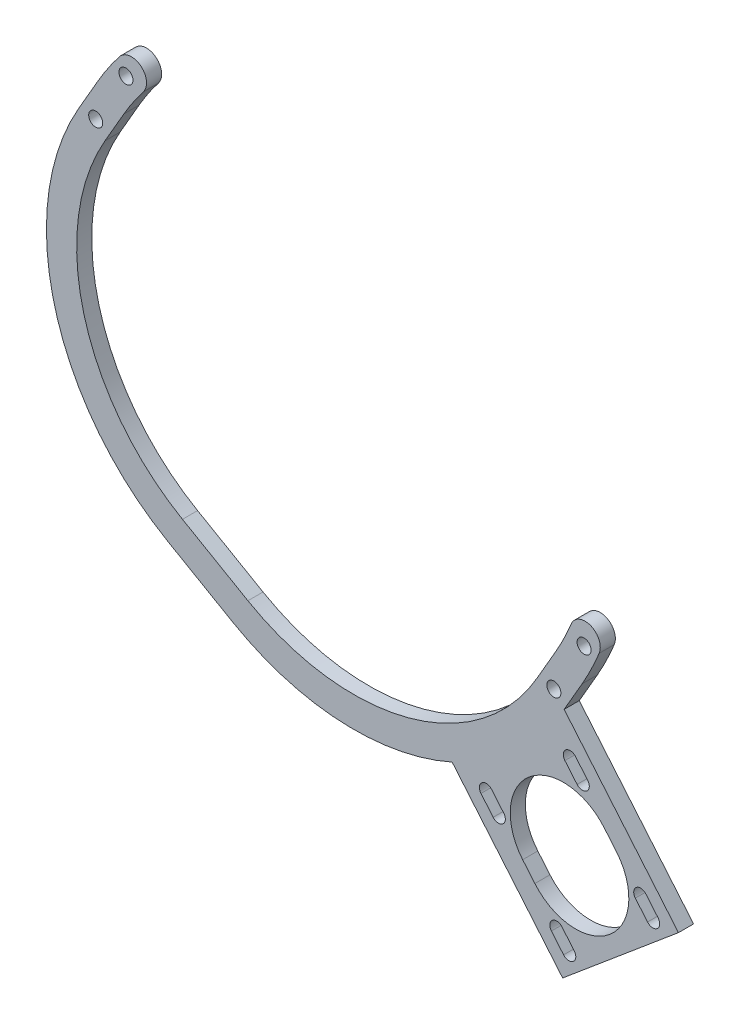
from build123d import *

# Parameters (mm, degrees)
BOSS_EXTRUDE1_DEPTH   = 3.175
BOSS_EXTRUDE2_DEPTH   = 3.175
F_4_CLEARANCE_HOLE1_D = 2.9464


with BuildPart() as part:
    # Sketch1 → Boss-Extrude1 (new body)
    with BuildSketch(Plane(origin=(0, 0, -14.15699402), x_dir=(-1, 0, 0), z_dir=(0, 0, -1))):
        with BuildLine():
            Line((-49.172312317, -34.502108483), (-53.141062317, -27.628031841))
            ThreePointArc((-53.141062317, -27.628031841), (-55.063803638, -24.012221257), (-56.72992661, -20.271224785))
            ThreePointArc((-56.72992661, -20.271224785), (-54.976138042, -16.13776671), (-50.842679967, -17.891555277))
            ThreePointArc((-50.842679967, -17.891555277), (-49.356678398, -21.228119699), (-47.641801003, -24.453031841))
            Line((-47.641801003, -24.453031841), (-43.673051003, -31.327108483))
            ThreePointArc((-43.673051003, -31.327108483), (-16.68272836, -52.037511462), (17.046778195, -47.596937682))
            Line((17.046778195, -47.596937682), (23.920854837, -43.628187682))
            Line((23.920854837, -43.628187682), (30.79493148, -39.659437682))
            ThreePointArc((30.79493148, -39.659437682), (51.505334458, -12.669115038), (47.064760678, 21.060391517))
            Line((47.064760678, 21.060391517), (43.096010678, 27.934468159))
            ThreePointArc((43.096010678, 27.934468159), (41.160593535, 31.032051618), (39.01404477, 33.987248938))
            ThreePointArc((39.01404477, 33.987248938), (39.561948355, 38.44382292), (44.018522337, 37.895919335))
            ThreePointArc((44.018522337, 37.895919335), (46.425258832, 34.58251628), (48.595271992, 31.109468159))
            Line((48.595271992, 31.109468159), (52.564021992, 24.235391517))
            ThreePointArc((52.564021992, 24.235391517), (57.638963455, -14.312615975), (33.96993148, -45.158698996))
            Line((33.96993148, -45.158698996), (27.095854837, -49.127448996))
            Line((27.095854837, -49.127448996), (20.221778195, -53.096198996))
            ThreePointArc((20.221778195, -53.096198996), (-18.326229296, -58.171140459), (-49.172312317, -34.502108483))
        make_face()
    extrude(amount=BOSS_EXTRUDE1_DEPTH)

    # Sketch6 → Boss-Extrude2 (add)
    with BuildSketch(Plane.XY.offset(-14.15699402)):
        Polygon((73.386475357, -62.761479903), (49.064564288, -83.169986511), (23.03238373, -52.146041808), (47.354294799, -31.7375352), align=None)
        with BuildLine():
            Line((57.786630634, -51.480655173), (60.349939064, -54.535487203))
            ThreePointArc((60.349939064, -54.535487203), (58.972420693, -70.280594225), (43.227313671, -68.903075855))
            Line((43.227313671, -68.903075855), (40.664005241, -65.848243824))
            ThreePointArc((40.664005241, -65.848243824), (42.041523612, -50.103136802), (57.786630634, -51.480655173))
        make_face(mode=Mode.SUBTRACT)
        with BuildLine():
            Line((49.261329446, -78.860212796), (46.698021016, -75.805380766))
            ThreePointArc((46.698021016, -75.805380766), (46.876472259, -73.76567372), (48.916179305, -73.944124963))
            Line((48.916179305, -73.944124963), (51.479487735, -76.998956993))
            ThreePointArc((51.479487735, -76.998956993), (51.301036492, -79.03866404), (49.261329446, -78.860212796))
        make_face(mode=Mode.SUBTRACT)
        with BuildLine():
            Line((34.124093716, -56.31560382), (36.687402146, -59.370435851))
            ThreePointArc((36.687402146, -59.370435851), (36.508950903, -61.410142897), (34.469243857, -61.231691653))
            Line((34.469243857, -61.231691653), (31.905935427, -58.176859623))
            ThreePointArc((31.905935427, -58.176859623), (32.08438667, -56.137152577), (34.124093716, -56.31560382))
        make_face(mode=Mode.SUBTRACT)
        with BuildLine():
            Line((51.752614859, -41.523518231), (54.315923289, -44.578350261))
            ThreePointArc((54.315923289, -44.578350261), (54.137472045, -46.618057308), (52.097764999, -46.439606064))
            Line((52.097764999, -46.439606064), (49.534456569, -43.384774034))
            ThreePointArc((49.534456569, -43.384774034), (49.712907813, -41.345066988), (51.752614859, -41.523518231))
        make_face(mode=Mode.SUBTRACT)
        with BuildLine():
            Line((66.544700448, -59.152039374), (69.108008878, -62.206871404))
            ThreePointArc((69.108008878, -62.206871404), (68.929557635, -64.24657845), (66.889850589, -64.068127207))
            Line((66.889850589, -64.068127207), (64.326542159, -61.013295177))
            ThreePointArc((64.326542159, -61.013295177), (64.504993402, -58.973588131), (66.544700448, -59.152039374))
        make_face(mode=Mode.SUBTRACT)
    extrude(amount=-BOSS_EXTRUDE2_DEPTH)

    # 4 Clearance Hole1 (through all)
    with Locations(Plane(origin=(0, 0, -17.33199402), x_dir=(-1, 0, 0), z_dir=(0, 0, -1))):
        with Locations((-53.56643166, -20.541270527), (-47.21643166, -31.539793155), (42.670641335, 35.021229473), (49.020641335, 24.022706845)):
            Hole(F_4_CLEARANCE_HOLE1_D / 2)


solid = part.part
